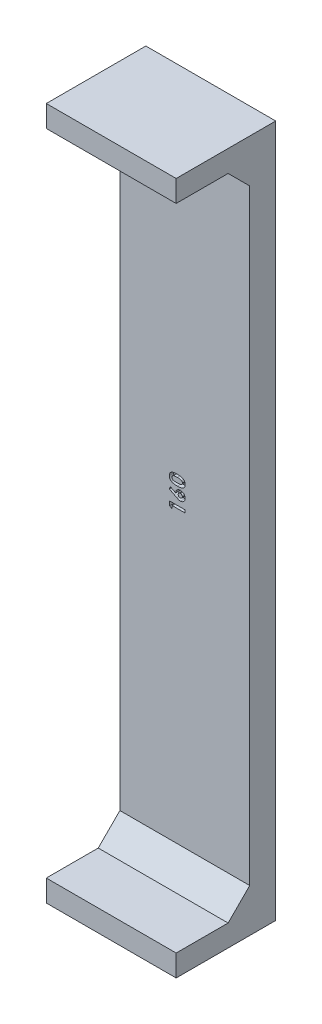
from build123d import *

# Parameters (mm, degrees)
SKETCH1_W           = 30
SKETCH1_H           = 159.95
BOSS_EXTRUDE1_DEPTH = 3
SKETCH2_W           = 30
SKETCH2_H           = 5
BOSS_EXTRUDE2_DEPTH = 20
SKETCH3_W           = 30
SKETCH3_H           = 5
BOSS_EXTRUDE3_DEPTH = 20
CHAMFER1_SIZE       = 5
CUT_EXTRUDE1_DEPTH  = 1


with BuildPart() as part:
    # Sketch1 → Boss-Extrude1 (new body, symmetric)
    with BuildSketch(Plane.XY):
        with Locations((0, 79.975)):
            Rectangle(SKETCH1_W, SKETCH1_H)
    extrude(amount=BOSS_EXTRUDE1_DEPTH, both=True)

    # Sketch2 → Boss-Extrude2 (add)
    with BuildSketch(Plane.XY):
        with Locations((0, 2.5)):
            Rectangle(SKETCH2_W, SKETCH2_H)
    extrude(amount=BOSS_EXTRUDE2_DEPTH)

    # Sketch3 → Boss-Extrude3 (add)
    with BuildSketch(Plane.XY):
        with Locations((0, 157.45)):
            Rectangle(SKETCH3_W, SKETCH3_H)
    extrude(amount=BOSS_EXTRUDE3_DEPTH)

    # Chamfer1
    chamfer1_edges = [part.edges().sort_by_distance(p)[0] for p in [
        (0, 5, 3),
        (0, 154.95, 3),
    ]]
    chamfer(chamfer1_edges, length=CHAMFER1_SIZE)

    # Sketch4 → Cut-Extrude1 (cut)
    with BuildSketch(Plane.XY.offset(3)):
        Polygon((-3.5, 76.715484776), (-3.5, 77.686538462), (0, 77.686538462), (0, 77.058333333), (-2.916666667, 77.058333333), (-2.916666667, 76.340384615), align=None)
        with BuildLine():
            Line((-3.58974359, 80.050721154), (-3.307892628, 80.606710737))
            Line((-3.307892628, 80.606710737), (-2.108974359, 79.996734776))
            add(Edge.make_bspline(
                [(-2.108974359, 79.996734776), (-2.108048145, 80.032774225), (-2.106223816, 80.103759832), (-2.091273634, 80.208155216), (-2.065936314, 80.308212598), (-2.030576693, 80.40392784), (-1.986153018, 80.495984524), (-1.931481503, 80.583935755), (-1.86526531, 80.666610454), (-1.791766129, 80.745551015), (-1.710377004, 80.817346015), (-1.622911973, 80.879708832), (-1.531510742, 80.934057934), (-1.434125355, 80.976306496), (-1.332370898, 81.010385659), (-1.225840394, 81.034975258), (-1.114225415, 81.049004317), (-1.038400302, 81.050938456), (-0.999799679, 81.051923077)],
                knots=[0, 0, 0, 0, 0.000108084, 0.00021289, 0.000315599, 0.000417191, 0.000518476, 0.000621779, 0.000727118, 0.000835746, 0.000945036, 0.001052051, 0.001157629, 0.001263415, 0.001369838, 0.001479197, 0.001590859, 0.001706648, 0.001706648, 0.001706648, 0.001706648], degree=3))
            add(Edge.make_bspline(
                [(-0.999799679, 81.051923077), (-0.962592079, 81.050997587), (-0.889048608, 81.049168291), (-0.781013621, 81.034133442), (-0.677215804, 81.009571051), (-0.577961777, 80.975260289), (-0.483258335, 80.930438977), (-0.392589309, 80.876566988), (-0.306658059, 80.81208721), (-0.225999088, 80.739007434), (-0.152483585, 80.659103744), (-0.087137228, 80.574884754), (-0.033159024, 80.48563215), (0.012426931, 80.393034109), (0.046443906, 80.295385529), (0.072120836, 80.19414781), (0.086937537, 80.088553213), (0.088800754, 80.016878308), (0.08974359, 79.980608974)],
                knots=[0, 0, 0, 0, 0.000111586, 0.000220558, 0.000326504, 0.000431162, 0.000534978, 0.000640309, 0.00074702, 0.000856721, 0.000966376, 0.001072392, 0.001175923, 0.001278776, 0.001381449, 0.001485517, 0.001591711, 0.001700496, 0.001700496, 0.001700496, 0.001700496], degree=3))
            add(Edge.make_bspline(
                [(0.08974359, 79.980608974), (0.088962962, 79.942684958), (0.087427962, 79.86811251), (0.070489961, 79.758948399), (0.044503734, 79.654504837), (0.009209971, 79.554356319), (-0.038694064, 79.459750325), (-0.096096067, 79.369879466), (-0.164318672, 79.285102697), (-0.241319005, 79.205972343), (-0.325698602, 79.134696309), (-0.41329732, 79.071120204), (-0.504263946, 79.017335689), (-0.598498296, 78.97379814), (-0.695700846, 78.939829195), (-0.796055878, 78.916193723), (-0.899297254, 78.900793035), (-0.969362693, 78.898987655), (-1.004707532, 78.898076923)],
                knots=[0, 0, 0, 0, 0.000113688, 0.000223552, 0.000330511, 0.000436297, 0.000541337, 0.000647916, 0.000755661, 0.000867219, 0.000978629, 0.001086622, 0.001191596, 0.001295116, 0.001397556, 0.00149993, 0.001604041, 0.001710024, 0.001710024, 0.001710024, 0.001710024], degree=3))
            add(Edge.make_bspline(
                [(-1.004707532, 78.898076923), (-1.032077983, 78.898558119), (-1.086971239, 78.899523189), (-1.169170777, 78.909222173), (-1.251586612, 78.923966636), (-1.321129985, 78.941061812), (-1.379940422, 78.958653997), (-1.429695831, 78.97639587), (-1.484778053, 78.998144501), (-1.54538714, 79.023774721), (-1.612000557, 79.052223548), (-1.683837124, 79.085294809), (-1.761469825, 79.121911517), (-1.814772946, 79.148068741), (-1.842548077, 79.161698718)],
                knots=[0, 0, 0, 0, 8.2079e-05, 0.000164615, 0.000247957, 0.000333152, 0.000379287, 0.000432063, 0.000491563, 0.000556929, 0.000629474, 0.000708853, 0.00079416, 0.000886976, 0.000886976, 0.000886976, 0.000886976], degree=3))
            Line((-1.842548077, 79.161698718), (-3.58974359, 80.050721154))
        make_face()
        with BuildLine():
            add(Edge.make_bspline(
                [(-1.525641026, 79.966586538), (-1.524255618, 79.936445844), (-1.521544556, 79.877464462), (-1.493250213, 79.793559347), (-1.448728493, 79.717361922), (-1.387579467, 79.650622663), (-1.313420818, 79.595211775), (-1.228668225, 79.554808531), (-1.134858814, 79.530114154), (-1.069366025, 79.52758676), (-1.035556891, 79.526282051)],
                knots=[0, 0, 0, 0, 9.0137e-05, 0.000176386, 0.000262485, 0.00035332, 0.000446009, 0.00053852, 0.00063341, 0.000734665, 0.000734665, 0.000734665, 0.000734665], degree=3))
            add(Edge.make_bspline(
                [(-1.035556891, 79.526282051), (-1.001744589, 79.527847891), (-0.935977402, 79.530893554), (-0.841574321, 79.5561353), (-0.755654275, 79.598113768), (-0.680875852, 79.656531763), (-0.617897902, 79.72462908), (-0.571952081, 79.800911321), (-0.543645634, 79.883087906), (-0.540201502, 79.939958877), (-0.538461538, 79.968689904)],
                knots=[0, 0, 0, 0, 0.000101311, 0.000197058, 0.000290812, 0.000386311, 0.000480117, 0.000567533, 0.000651784, 0.000737805, 0.000737805, 0.000737805, 0.000737805], degree=3))
            add(Edge.make_bspline(
                [(-0.538461538, 79.968689904), (-0.540235151, 79.999030592), (-0.543713513, 80.058533951), (-0.570791831, 80.14437407), (-0.616040201, 80.222779006), (-0.678046867, 80.292145488), (-0.752042934, 80.351439157), (-0.838605768, 80.393198019), (-0.934009126, 80.419364433), (-1.001025749, 80.422237543), (-1.035556891, 80.423717949)],
                knots=[0, 0, 0, 0, 9.0903e-05, 0.000178276, 0.000267153, 0.000360547, 0.000455923, 0.000549677, 0.000646958, 0.000750366, 0.000750366, 0.000750366, 0.000750366], degree=3))
            add(Edge.make_bspline(
                [(-1.035556891, 80.423717949), (-1.069346543, 80.422084462), (-1.134784149, 80.418921024), (-1.22902784, 80.394827025), (-1.313463746, 80.352487252), (-1.387889648, 80.295814658), (-1.448997728, 80.226797601), (-1.493602865, 80.147540452), (-1.521493736, 80.059802802), (-1.52423844, 79.998111659), (-1.525641026, 79.966586538)],
                knots=[0, 0, 0, 0, 0.000101311, 0.000196202, 0.000289327, 0.00038286, 0.000475265, 0.000563795, 0.000654055, 0.000748381, 0.000748381, 0.000748381, 0.000748381], degree=3))
        make_face(mode=Mode.SUBTRACT)
        with BuildLine():
            add(Edge.make_bspline(
                [(-3.58974359, 82.724098558), (-3.589292271, 82.754506341), (-3.588404858, 82.814296167), (-3.578790152, 82.902354508), (-3.564271859, 82.987182181), (-3.543999646, 83.069096387), (-3.517257205, 83.147560747), (-3.48497957, 83.222849752), (-3.446862082, 83.294895479), (-3.40272949, 83.363774239), (-3.351900364, 83.428870811), (-3.295858171, 83.491237714), (-3.232437061, 83.548374301), (-3.163278345, 83.602007075), (-3.087968534, 83.651769743), (-3.006726967, 83.697983679), (-2.919052238, 83.7401882), (-2.8248155, 83.778886683), (-2.722595803, 83.813489217), (-2.611223065, 83.842635383), (-2.490671145, 83.867632949), (-2.360640179, 83.888732702), (-2.220957263, 83.904680694), (-2.071715214, 83.915429964), (-1.913201744, 83.922806621), (-1.804462806, 83.923408653), (-1.748597756, 83.923717949)],
                knots=[0, 0, 0, 0, 9.1189e-05, 0.000179302, 0.000265406, 0.000349239, 0.000432161, 0.00051382, 0.000594738, 0.000676421, 0.000758883, 0.000842266, 0.00092763, 0.001014581, 0.001104614, 0.001198187, 0.001294769, 0.001396325, 0.001503636, 0.00161826, 0.001741466, 0.001872868, 0.00201332, 0.00216308, 0.002321688, 0.00248927, 0.00248927, 0.00248927, 0.00248927], degree=3))
            add(Edge.make_bspline(
                [(-1.748597756, 83.923717949), (-1.692033787, 83.923383628), (-1.58213101, 83.92273405), (-1.422167485, 83.915737204), (-1.27184258, 83.903684399), (-1.131167681, 83.888162129), (-1.000231201, 83.866858701), (-0.87886747, 83.842091212), (-0.767053574, 83.812219597), (-0.664780375, 83.776676844), (-0.570287572, 83.737918791), (-0.482436028, 83.696270389), (-0.401877539, 83.649925503), (-0.32606073, 83.603107875), (-0.258300114, 83.550593483), (-0.195929558, 83.496270904), (-0.141336019, 83.437379383), (-0.091662801, 83.376467502), (-0.048737202, 83.311285835), (-0.011194638, 83.242511246), (0.019256701, 83.168916355), (0.04574169, 83.091843008), (0.064755045, 83.009977383), (0.07984152, 82.924620338), (0.088179231, 82.834808202), (0.089213579, 82.773660483), (0.08974359, 82.742327724)],
                knots=[0, 0, 0, 0, 0.000169685, 0.000329694, 0.000480207, 0.000622052, 0.000754146, 0.000878038, 0.000993521, 0.001101058, 0.001202615, 0.001299828, 0.001392445, 0.001481333, 0.001566873, 0.001649319, 0.001729177, 0.001807467, 0.001884861, 0.001962975, 0.002042149, 0.002123519, 0.002207185, 0.00229398, 0.002383419, 0.002477411, 0.002477411, 0.002477411, 0.002477411], degree=3))
            add(Edge.make_bspline(
                [(0.08974359, 82.742327724), (0.089203248, 82.710995868), (0.088144727, 82.649617222), (0.0799047, 82.559561431), (0.064689711, 82.473754894), (0.04561087, 82.39123134), (0.019260303, 82.312625498), (-0.011888655, 82.237239569), (-0.050195239, 82.166564249), (-0.093036225, 82.099143268), (-0.142407932, 82.036041441), (-0.197534612, 81.976323365), (-0.257643528, 81.919153699), (-0.324823351, 81.866569215), (-0.397846917, 81.817629407), (-0.476704111, 81.771814898), (-0.561652697, 81.73005628), (-0.652669715, 81.690957007), (-0.751939101, 81.656365001), (-0.860394285, 81.626536082), (-0.978847477, 81.601270748), (-1.107180138, 81.581413421), (-1.24540934, 81.565400254), (-1.393424176, 81.553525202), (-1.551279305, 81.546485708), (-1.659781601, 81.545843479), (-1.715645032, 81.545512821)],
                knots=[0, 0, 0, 0, 9.3992e-05, 0.000184129, 0.000270924, 0.000355272, 0.000437971, 0.000519356, 0.000599655, 0.00067881, 0.000758751, 0.000839635, 0.000922466, 0.001007327, 0.001095222, 0.001186014, 0.001280707, 0.001379029, 0.001483025, 0.001595803, 0.001716266, 0.001846172, 0.001985231, 0.002133647, 0.002291555, 0.002459137, 0.002459137, 0.002459137, 0.002459137], degree=3))
            add(Edge.make_bspline(
                [(-1.715645032, 81.545512821), (-1.793262797, 81.546112178), (-1.943027275, 81.547268647), (-2.159393402, 81.561924267), (-2.359386406, 81.583435001), (-2.542671749, 81.615029173), (-2.709928265, 81.65409493), (-2.860054156, 81.704120666), (-2.995126752, 81.761071327), (-3.075144571, 81.809600607), (-3.113681891, 81.832972756)],
                knots=[0, 0, 0, 0, 0.00023281, 0.000449211, 0.000650286, 0.000835979, 0.001006883, 0.001164965, 0.001310334, 0.001445389, 0.001445389, 0.001445389, 0.001445389], degree=3))
            add(Edge.make_bspline(
                [(-3.113681891, 81.832972756), (-3.151540942, 81.860148778), (-3.225562848, 81.913283256), (-3.322739774, 82.006190376), (-3.405850239, 82.10600698), (-3.47301338, 82.214783244), (-3.525978238, 82.330798826), (-3.563386721, 82.45504978), (-3.585182647, 82.587077267), (-3.588200572, 82.677742744), (-3.58974359, 82.724098558)],
                knots=[0, 0, 0, 0, 0.000139664, 0.000273071, 0.000402072, 0.00052834, 0.000655415, 0.000783615, 0.000916514, 0.00105555, 0.00105555, 0.00105555, 0.00105555], degree=3))
        make_face()
        with BuildLine():
            add(Edge.make_bspline(
                [(-2.961538462, 82.739523237), (-2.960231555, 82.712037211), (-2.957669325, 82.658150008), (-2.936043186, 82.579908696), (-2.902387653, 82.506448693), (-2.862903934, 82.449949797), (-2.824255084, 82.408140095), (-2.789315635, 82.378791128), (-2.750296463, 82.350500595), (-2.705457779, 82.325542793), (-2.656279988, 82.301736215), (-2.602621424, 82.279189787), (-2.543608144, 82.259802835), (-2.479637432, 82.241312579), (-2.409160442, 82.22532086), (-2.331496301, 82.2113282), (-2.24637985, 82.199407817), (-2.15345432, 82.190810623), (-2.053206644, 82.182916852), (-1.945204531, 82.177233072), (-1.829470671, 82.174862071), (-1.749766756, 82.174107409), (-1.708633814, 82.173717949)],
                knots=[0, 0, 0, 0, 8.233e-05, 0.000161411, 0.000241719, 0.000323799, 0.000366956, 0.000412204, 0.000460454, 0.000511328, 0.00056589, 0.000624352, 0.000685768, 0.000752123, 0.000824066, 0.000902453, 0.000988817, 0.001081812, 0.001182369, 0.001290487, 0.001406206, 0.001529612, 0.001529612, 0.001529612, 0.001529612], degree=3))
            add(Edge.make_bspline(
                [(-1.708633814, 82.173717949), (-1.655344362, 82.174360546), (-1.553157887, 82.175592773), (-1.406205495, 82.182003648), (-1.272252935, 82.195005735), (-1.150781885, 82.210798303), (-1.042500524, 82.233605048), (-0.946446975, 82.259414662), (-0.863482937, 82.291444701), (-0.792612725, 82.328443629), (-0.732324207, 82.369425528), (-0.681078549, 82.413912276), (-0.636702263, 82.460390305), (-0.600655943, 82.510310091), (-0.573031708, 82.563552601), (-0.553161936, 82.619673343), (-0.540998822, 82.678707986), (-0.539312189, 82.7191343), (-0.538461538, 82.739523237)],
                knots=[0, 0, 0, 0, 0.00015988, 0.000306582, 0.00044109, 0.000563546, 0.000673825, 0.00077283, 0.000861626, 0.00094003, 0.001012177, 0.001079783, 0.001143273, 0.001204564, 0.001263832, 0.001322597, 0.001382685, 0.001443828, 0.001443828, 0.001443828, 0.001443828], degree=3))
            add(Edge.make_bspline(
                [(-0.538461538, 82.739523237), (-0.539043617, 82.759212491), (-0.540183253, 82.7977616), (-0.551881469, 82.853974836), (-0.570900227, 82.907134066), (-0.597803595, 82.957078786), (-0.632015344, 83.003987641), (-0.673685815, 83.04763137), (-0.723230366, 83.08768082), (-0.759999749, 83.111013812), (-0.778946314, 83.123036859)],
                knots=[0, 0, 0, 0, 5.8998e-05, 0.000115512, 0.000171399, 0.00022786, 0.000285078, 0.000345085, 0.000408376, 0.000475658, 0.000475658, 0.000475658, 0.000475658], degree=3))
            add(Edge.make_bspline(
                [(-0.778946314, 83.123036859), (-0.804836189, 83.137191972), (-0.859125158, 83.166874096), (-0.950735767, 83.201222302), (-1.054057394, 83.230134707), (-1.169411585, 83.255019191), (-1.29725331, 83.27203866), (-1.436771915, 83.286695806), (-1.588669958, 83.293765312), (-1.69390547, 83.294915206), (-1.748597756, 83.295512821)],
                knots=[0, 0, 0, 0, 8.843e-05, 0.000185431, 0.00029262, 0.000410194, 0.000539093, 0.000679319, 0.000830958, 0.000995045, 0.000995045, 0.000995045, 0.000995045], degree=3))
            add(Edge.make_bspline(
                [(-1.748597756, 83.295512821), (-1.803764798, 83.295281975), (-1.909951935, 83.294837636), (-2.062396063, 83.286685309), (-2.201628473, 83.275332571), (-2.327338316, 83.258726792), (-2.439830761, 83.23736044), (-2.539098454, 83.21102633), (-2.625337033, 83.179980373), (-2.698460505, 83.143163568), (-2.760605426, 83.10238667), (-2.813920947, 83.059100747), (-2.859440394, 83.013122769), (-2.897335064, 82.964529627), (-2.926289435, 82.912196616), (-2.946733616, 82.857123363), (-2.959101659, 82.799196965), (-2.960715231, 82.759682961), (-2.961538462, 82.739523237)],
                knots=[0, 0, 0, 0, 0.000165478, 0.000318517, 0.00045785, 0.000584474, 0.000698739, 0.000801125, 0.000892295, 0.000973192, 0.001046115, 0.001114882, 0.001178838, 0.00123984, 0.001299154, 0.001357499, 0.001415527, 0.00147597, 0.00147597, 0.00147597, 0.00147597], degree=3))
        make_face(mode=Mode.SUBTRACT)
    extrude(amount=-CUT_EXTRUDE1_DEPTH, mode=Mode.SUBTRACT)


solid = part.part
